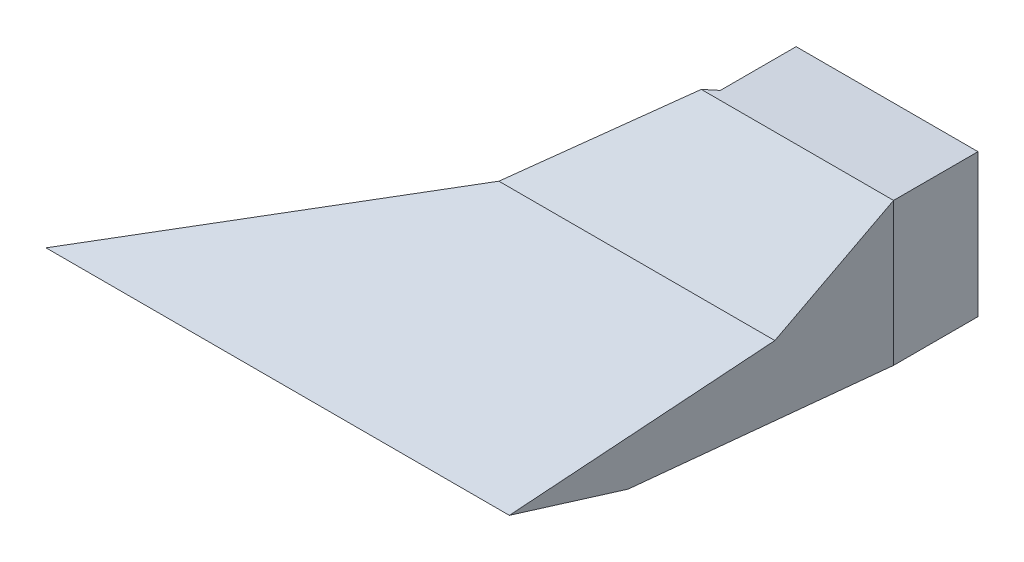
from build123d import *

# Parameters (mm, degrees)
SIDE_BASE_DEPTH                    = 0.8
SIDE_BASE_2_COUNT                  = 2
SIDE_BASE_2_PITCH                  = 50
FRONT_BACK_WALLS_DEPTH             = 50
BASE_SKETCH_W                      = 50.8
BASE_SKETCH_H                      = 13.2
BASE_SKETCH_W_2                    = 15.2
BASE_SKETCH_H_2                    = 11.276834123
BASE_DEPTH                         = 0.8
ATTACHMENT_BASE_SKETCH_W           = 16.8
ATTACHMENT_BASE_SKETCH_H           = 13.2
ATTACHMENT_BASE_SKETCH_W_2         = 15.2
ATTACHMENT_BASE_SKETCH_H_2         = 11.276834123
ATTACHMENT_BASE_DEPTH              = 7
LEFT_RIGHT_WALL_REMOVAL_DEPTH      = 51
LEFT_RIGHT_WALL_REMOVAL_DEPTH_BACK = 1.8
SKETCH6_W                          = 28.631700026
SKETCH6_H                          = 16.366666667
CUTAWAY_LEFT_DEPTH                 = 8.681373736
LEFT_WALL_DEPTH                    = 0.8331843
SKETCH9_W                          = 44.231215268
SKETCH9_H                          = 16.366666667
CUTAWAY_RIGHT_DEPTH                = 28.12803264
RIGHT_WALL_DEPTH                   = 1.25073473
PIPE_TOP_EXTRA_CUTAWAY_REACH       = 37.291
SKETCH11_W                         = 15.2
SKETCH11_H                         = 0.312130873
SKETCH1_W                          = 15.2
SKETCH1_H                          = 11.588964996
FAN_BASE_DEPTH                     = 0.1


with BuildPart() as part:
    # Side base sketch → Side base (new body)
    with BuildSketch(Plane.ZY):
        Polygon((0, 13.2), (8.491348573, 5), (19.491348573, 0.8030407), (27.491348573, -2.249293336), (19, -3.166666667), (6, -1), (0, 0), align=None)
    extrude(amount=-SIDE_BASE_DEPTH)


with BuildPart() as side_base_2_1:
    # Side base 2: pattern copy
    add(part.part.moved(Location(Vector(1, 0, 0) * (1 * SIDE_BASE_2_PITCH))))


with BuildPart() as part_1:
    add(part.part)

    add(side_base_2_1.part)  # Front back walls merges Side base 2_1
    # Wall base sketch → Front back walls (add)
    with BuildSketch(Plane(origin=(0.8, 0, 0), x_dir=(0, 0, -1), z_dir=(1, 0, 0))):
        Polygon((0, 12.087869127), (-8.053310036, 4.310878025), (-25.742389296, -2.438244311), (-27.491348573, -2.249293336), (-8.491348573, 5), (0, 13.2), align=None)
        Polygon((0, 0.811035004), (-19, -2.355631663), (-19, -3.166666667), (0, 0), align=None)
    extrude(amount=FRONT_BACK_WALLS_DEPTH)

    # Base sketch → Base (add)
    with BuildSketch(Plane(origin=(0, 0, 0), x_dir=(-1, 0, 0), z_dir=(0, 0, -1))):
        with Locations((-25.4, 6.6)):
            Rectangle(BASE_SKETCH_W, BASE_SKETCH_H)
        with Locations((-42.4, 6.449452066)):
            Rectangle(BASE_SKETCH_W_2, BASE_SKETCH_H_2, mode=Mode.SUBTRACT)
    extrude(amount=BASE_DEPTH)

    # Attachment base sketch → Attachment base (add)
    with BuildSketch(Plane(origin=(0, 0, -0.8), x_dir=(-1, 0, 0), z_dir=(0, 0, -1))):
        with Locations((-42.4, 6.6)):
            Rectangle(ATTACHMENT_BASE_SKETCH_W, ATTACHMENT_BASE_SKETCH_H)
        with Locations((-42.4, 6.449452066)):
            Rectangle(ATTACHMENT_BASE_SKETCH_W_2, ATTACHMENT_BASE_SKETCH_H_2, mode=Mode.SUBTRACT)
    extrude(amount=ATTACHMENT_BASE_DEPTH)

    # Sketch4 → Left right wall removal (cut, two sides)
    with BuildSketch(Plane(origin=(0.8, 0, 0), x_dir=(0, 0, -1), z_dir=(1, 0, 0))) as left_right_wall_removal_sk:
        Polygon((-25.742389296, -2.438244311), (-19, -3.166666667), (-19, -2.355631663), (0, 0.811035004), (0, 12.087869127), (-8.053310036, 4.310878025), align=None)
    extrude(amount=LEFT_RIGHT_WALL_REMOVAL_DEPTH, mode=Mode.SUBTRACT)
    extrude(left_right_wall_removal_sk.sketch, amount=-LEFT_RIGHT_WALL_REMOVAL_DEPTH_BACK, mode=Mode.SUBTRACT)

    # Sketch6 → Cutaway left (cut, through all)
    with BuildSketch(Plane(origin=(46.834030083, 0, 13.628732678), x_dir=(0.279410583, 0, -0.960171717), z_dir=(0.960171717, 0, 0.279410583))):
        with Locations((-0.12179239, 5.016666667)):
            Rectangle(SKETCH6_W, SKETCH6_H)
    extrude(amount=CUTAWAY_LEFT_DEPTH, mode=Mode.SUBTRACT)

    # Sketch7 → Left wall (add, along a direction that is not the sketch's normal)
    with BuildSketch(Plane(origin=(46.834030083, 0, 13.628732678), x_dir=(0.279410583, 0, -0.960171717), z_dir=(0.960171717, 0, 0.279410583))):
        Polygon((-5.594069506, -2.355631663), (-5.594069506, -3.166666667), (-12.616135639, -2.438244311), (5.806693265, 4.310878025), (14.194057623, 12.087869127), (14.194057623, 0.811035004), align=None)
    extrude(amount=-LEFT_WALL_DEPTH, dir=(1, 0, 0))

    # Sketch9 → Cutaway right (cut, through all)
    with BuildSketch(Plane(origin=(13.516705988, 0, 16.244117965), x_dir=(0.7686879, 0, -0.639624039), z_dir=(0.639624039, 0, 0.7686879))):
        with Locations((4.531480214, 5.016666667)):
            Rectangle(SKETCH9_W, SKETCH9_H)
    extrude(amount=-CUTAWAY_RIGHT_DEPTH, mode=Mode.SUBTRACT)

    # Sketch10 → Right wall (add, along a direction that is not the sketch's normal)
    with BuildSketch(Plane(origin=(13.516705988, 0, 16.244117965), x_dir=(-0.7686879, 0, 0.639624039), z_dir=(-0.639624039, 0, -0.7686879))):
        Polygon((-25.396353118, 12.087869127), (-25.396353118, 0.811035004), (4.308596716, -2.355631663), (4.308596716, -3.166666667), (14.849772284, -2.438244311), (-12.805659927, 4.310878025), align=None)
    extrude(amount=-RIGHT_WALL_DEPTH, dir=(-1, 0, 0))

    # Pipe top extra cutaway: up to this face of the body (flat: up to its plane)
    pipe_top_extra_cutaway_end = Plane(part_1.part.faces().sort_by_distance((38.932680486, 7.953647195, 4.281112134))[0])
    # Sketch11 → Pipe top extra cutaway (cut, up to the picked face)
    with BuildSketch(Plane(origin=(0, 0, -7.8), x_dir=(-1, 0, 0), z_dir=(0, 0, -1)), mode=Mode.PRIVATE) as pipe_top_extra_cutaway_sk1:
        with Locations((-42.4, 12.243934564)):
            Rectangle(SKETCH11_W, SKETCH11_H)
    pipe_top_extra_cutaway_tool1 = split(extrude(pipe_top_extra_cutaway_sk1.sketch, amount=-PIPE_TOP_EXTRA_CUTAWAY_REACH, mode=Mode.PRIVATE), bisect_by=pipe_top_extra_cutaway_end, keep=Keep.BOTH, mode=Mode.PRIVATE)
    add(pipe_top_extra_cutaway_tool1.solids().sort_by_distance((42.4, 12.243935, -7.8))[0], mode=Mode.SUBTRACT)


with BuildPart() as body_2:
    # Sketch1 → Fan base (new body)
    with BuildSketch(Plane(origin=(0, 0, -7.8), x_dir=(-1, 0, 0), z_dir=(0, 0, -1))):
        with Locations((-42.4, 6.605517502)):
            Rectangle(SKETCH1_W, SKETCH1_H)
    extrude(amount=FAN_BASE_DEPTH)


solid = Compound([part_1.part, body_2.part])
